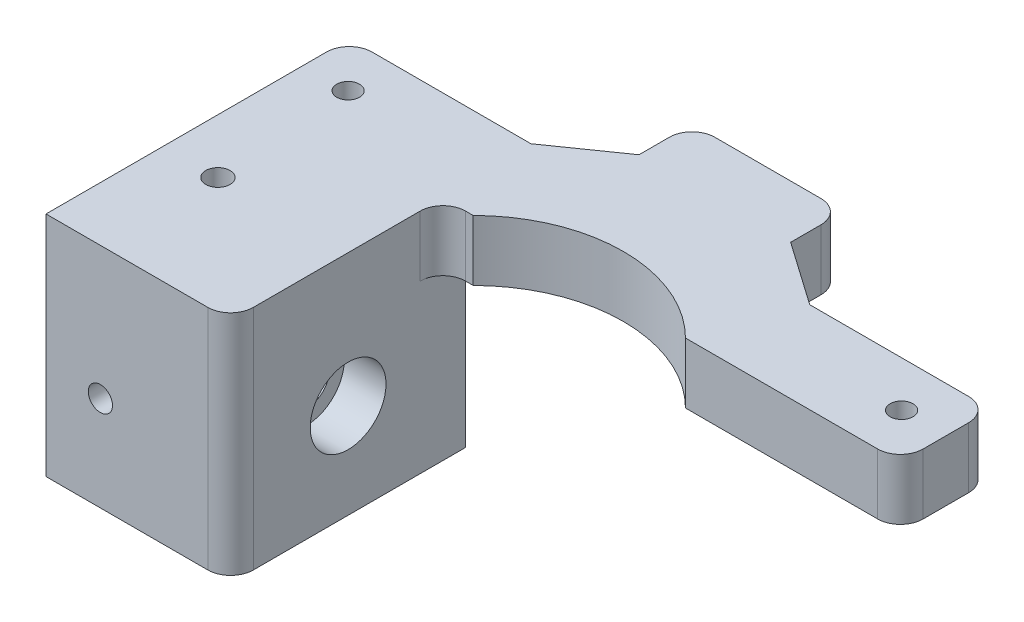
from build123d import *

# Parameters (mm, degrees)
SKETCH2_R           = 1.5
BOSS_EXTRUDE1_DEPTH = 8
SKETCH11_W          = 24.345630124
SKETCH11_H          = 31
BOSS_EXTRUDE4_DEPTH = 30
SKETCH12_W          = 25
SKETCH12_H          = 25
CUT_EXTRUDE7_DEPTH  = 14.34563
CUT_EXTRUDE8_REACH  = 26.346
SKETCH13_R          = 3.1
SKETCH14_R          = 5
CUT_EXTRUDE9_DEPTH  = 5.5
SKETCH15_R          = 1.6
CUT_EXTRUDE10_DEPTH = 5.5
CUT_EXTRUDE11_REACH = 32
SKETCH16_R          = 1.6
CUT_EXTRUDE12_DEPTH = 2.6
FILLET2_R           = 3


with BuildPart() as part:
    # Sketch2 → Boss-Extrude1 (new body)
    with BuildSketch(Plane(origin=(0, 0, 0), x_dir=(1, 0, 0), z_dir=(0, 1, 0))):
        with BuildLine():
            Line((-38.837197709, 64.4109018), (-14.876439197, 64.4109018))
            Line((-14.876439197, 64.4109018), (-6.491567585, 70.282052109))
            Line((-6.491567585, 70.282052109), (-6.491567585, 77.282052109))
            Line((-6.491567585, 77.282052109), (13.508432415, 77.282052109))
            Line((13.508432415, 77.282052109), (13.508432415, 70.282052109))
            Line((13.508432415, 70.282052109), (21.893304027, 64.4109018))
            Line((21.893304027, 64.4109018), (45.85406254, 64.4109018))
            Line((45.85406254, 64.4109018), (45.85406254, 52.4109018))
            Line((45.85406254, 52.4109018), (17.508432415, 52.4109018))
            ThreePointArc((17.508432415, 52.4109018), (3.508432415, 58.207416665), (-10.491567585, 52.4109018))
            Line((-10.491567585, 52.4109018), (-38.837197709, 52.4109018))
            Line((-38.837197709, 52.4109018), (-38.837197709, 64.4109018))
        make_face()
        with Locations((-32.991567585, 58.4109018)):
            Circle(SKETCH2_R, mode=Mode.SUBTRACT)
        with Locations((40.008432415, 58.4109018)):
            Circle(SKETCH2_R, mode=Mode.SUBTRACT)
    extrude(amount=BOSS_EXTRUDE1_DEPTH)

    # Sketch11 → Boss-Extrude4 (add)
    with BuildSketch(Plane(origin=(0, 8, 0), x_dir=(-1, 0, 0), z_dir=(0, -1, 0))):
        with Locations((26.664382647, 39.9109018)):
            Rectangle(SKETCH11_W, SKETCH11_H)
    extrude(amount=BOSS_EXTRUDE4_DEPTH)

    # Sketch12 → Cut-Extrude7 (cut)
    with BuildSketch(Plane.ZY.offset(38.837197709)):
        with Locations((-39.9109018, -9.5)):
            Rectangle(SKETCH12_W, SKETCH12_H)
    extrude(amount=-CUT_EXTRUDE7_DEPTH, mode=Mode.SUBTRACT)

    # Sketch13 → Cut-Extrude8 (cut, up to next)
    with BuildSketch(Plane(origin=(-14.491567585, 0, 0), x_dir=(0, 0, -1), z_dir=(1, 0, 0)), mode=Mode.PRIVATE) as cut_extrude8_sk1:
        with Locations((39.9109018, -9.5)):
            Circle(SKETCH13_R)
    cut_extrude8_tool1 = extrude(cut_extrude8_sk1.sketch, amount=-CUT_EXTRUDE8_REACH, mode=Mode.PRIVATE) & part.part
    add(cut_extrude8_tool1.solids().sort_by_distance((-14.491568, -9.5, -39.910902))[0], mode=Mode.SUBTRACT)

    # Sketch14 → Cut-Extrude9 (cut)
    with BuildSketch(Plane(origin=(-14.491567585, 0, 0), x_dir=(0, 0, -1), z_dir=(1, 0, 0))):
        with Locations((39.9109018, -9.5)):
            Circle(SKETCH14_R)
    extrude(amount=-CUT_EXTRUDE9_DEPTH, mode=Mode.SUBTRACT)

    # Sketch15 → Cut-Extrude10 (cut)
    with BuildSketch(Plane.XY.offset(-24.4109018)):
        with Locations((-31.664382647, -9.5)):
            Circle(SKETCH15_R)
    extrude(amount=-CUT_EXTRUDE10_DEPTH, mode=Mode.SUBTRACT)

    # Sketch16 → Cut-Extrude11 (cut, up to next)
    with BuildSketch(Plane(origin=(0, 8, 0), x_dir=(1, 0, 0), z_dir=(0, 1, 0)), mode=Mode.PRIVATE) as cut_extrude11_sk1:
        with Locations((-31.664382647, 39.9109018)):
            Circle(SKETCH16_R)
    cut_extrude11_tool1 = extrude(cut_extrude11_sk1.sketch, amount=-CUT_EXTRUDE11_REACH, mode=Mode.PRIVATE) & part.part
    add(cut_extrude11_tool1.solids().sort_by_distance((-31.664383, 8, -39.910902))[0], mode=Mode.SUBTRACT)

    # Sketch17 → Cut-Extrude12 (cut)
    with BuildSketch(Plane.XZ):
        Polygon((-31.259516777, -61.4109018), (-29.52746597, -58.4109018), (-31.259516777, -55.4109018), (-34.723618392, -55.4109018), (-36.4556692, -58.4109018), (-34.723618392, -61.4109018), align=None)
        Polygon((38.276381608, -61.4109018), (41.740483223, -61.4109018), (43.47253403, -58.4109018), (41.740483223, -55.4109018), (38.276381608, -55.4109018), (36.5443308, -58.4109018), align=None)
    extrude(amount=-CUT_EXTRUDE12_DEPTH, mode=Mode.SUBTRACT)

    # Fillet2
    fillet2_edges = [part.edges().sort_by_distance(p)[0] for p in [
        (-38.837197709, 4, -64.4109018),
        (-6.491567585, 4, -77.282052109),
        (13.508432415, 4, -77.282052109),
        (45.85406254, 4, -64.4109018),
        (45.85406254, 4, -52.4109018),
        (-14.491567585, 4, -52.4109018),
        (-14.491567585, -7, -24.4109018),
    ]]
    fillet(fillet2_edges, radius=FILLET2_R)


solid = part.part
